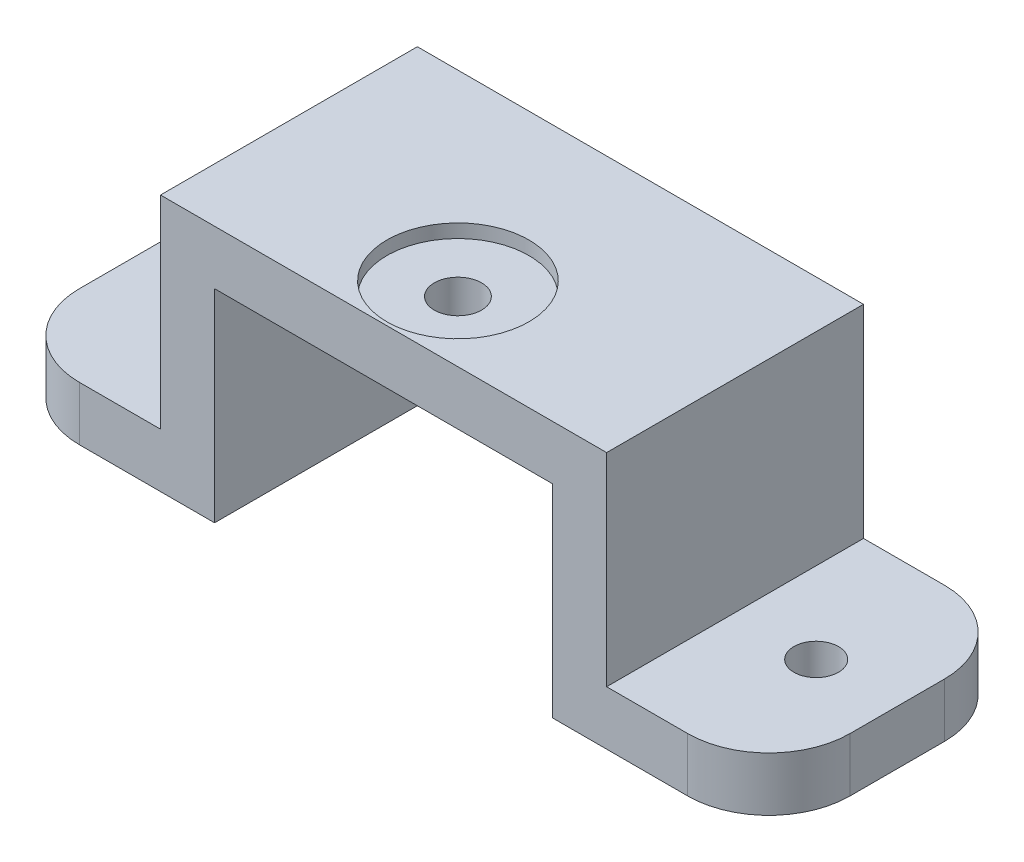
from build123d import *

# Parameters (mm, degrees)
RESSALTO_EXTRUS_O1_DEPTH   = 19
ESBO_O2_R                  = 1.75
ESBO_O2_R_2                = 1.65
CORTE_EXTRUS_O1_DEPTH      = 1
CORTE_EXTRUS_O1_DEPTH_BACK = 20
FILETE1_R                  = 6
ESBO_O3_R                  = 5
CORTE_EXTRUS_O2_DEPTH      = 1
ESBO_O4_R                  = 5.25
CORTE_EXTRUS_O3_DEPTH      = 1


with BuildPart() as part:
    # Esboço1 → Ressalto-extrusão1 (new body)
    with BuildSketch(Plane.XY):
        Polygon((12.5, 15), (-12.5, 15), (-12.5, 0), (-28.5, 0), (-28.5, 4), (-16.5, 4), (-16.5, 19), (16.5, 19), (16.5, 4), (28.5, 4), (28.5, 0), (12.5, 0), align=None)
    extrude(amount=RESSALTO_EXTRUS_O1_DEPTH)

    # Esboço2 → Corte-extrusão1 (cut, two sides)
    with BuildSketch(Plane(origin=(0, 19, 0), x_dir=(1, 0, 0), z_dir=(0, 1, 0))) as corte_extrus_o1_sk:
        with Locations((0, -13.5)):
            Circle(ESBO_O2_R)
        with Locations((-22.5, -9.5)):
            Circle(ESBO_O2_R_2)
        with Locations((22.5, -9.5)):
            Circle(ESBO_O2_R_2)
    extrude(amount=CORTE_EXTRUS_O1_DEPTH, mode=Mode.SUBTRACT)
    extrude(corte_extrus_o1_sk.sketch, amount=-CORTE_EXTRUS_O1_DEPTH_BACK, mode=Mode.SUBTRACT)

    # Filete1
    filete1_edges = [part.edges().sort_by_distance(p)[0] for p in [
        (28.5, 2, 0),
        (-28.5, 2, 0),
        (-28.5, 2, 19),
        (28.5, 2, 19),
    ]]
    fillet(filete1_edges, radius=FILETE1_R)

    # Esboço3 → Corte-extrusão2 (cut)
    with BuildSketch(Plane.XZ):
        with Locations((-22.5, 9.5)):
            Circle(ESBO_O3_R)
        with Locations((22.5, 9.5)):
            Circle(ESBO_O3_R)
    extrude(amount=-CORTE_EXTRUS_O2_DEPTH, mode=Mode.SUBTRACT)

    # Esboço4 → Corte-extrusão3 (cut)
    with BuildSketch(Plane(origin=(0, 19, 0), x_dir=(1, 0, 0), z_dir=(0, 1, 0))):
        with Locations((0, -13.5)):
            Circle(ESBO_O4_R)
    extrude(amount=-CORTE_EXTRUS_O3_DEPTH, mode=Mode.SUBTRACT)


solid = part.part
